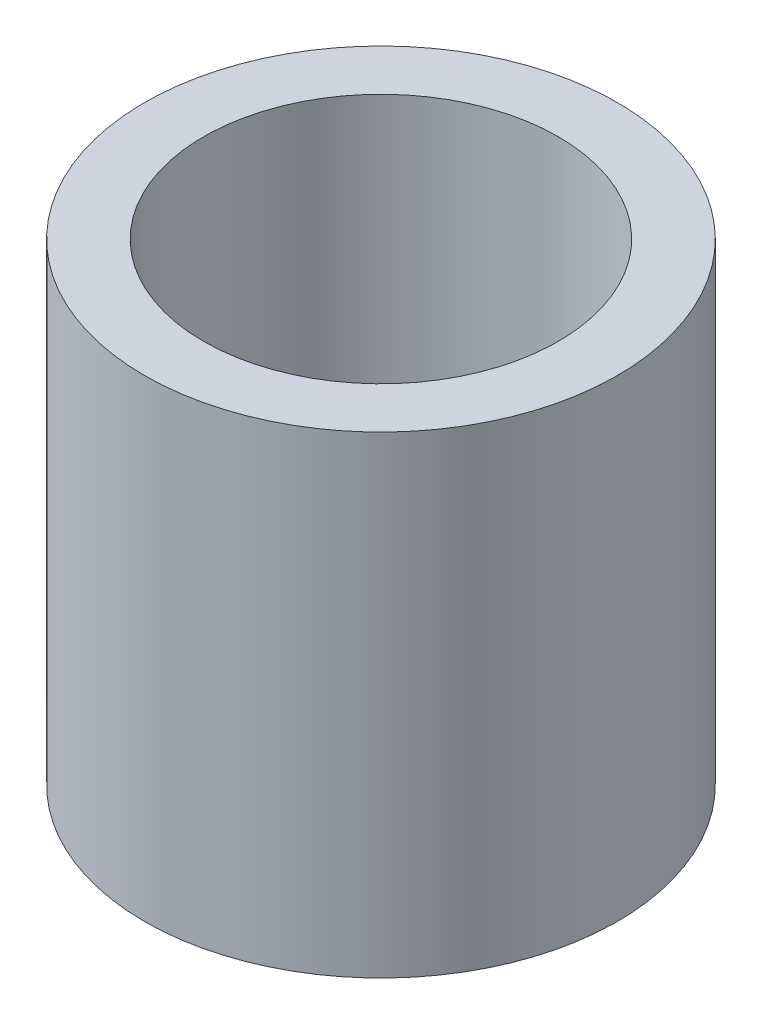
from build123d import *

# Parameters (mm, degrees)
SKETCH1_R           = 3.175
SKETCH1_R_2         = 2.38125
BOSS_EXTRUDE1_DEPTH = 6.35


with BuildPart() as part:
    # Sketch1 → Boss-Extrude1 (new body)
    with BuildSketch(Plane(origin=(0, 0, 0), x_dir=(1, 0, 0), z_dir=(0, 1, 0))):
        Circle(SKETCH1_R)
        Circle(SKETCH1_R_2, mode=Mode.SUBTRACT)
    extrude(amount=BOSS_EXTRUDE1_DEPTH)


solid = part.part
